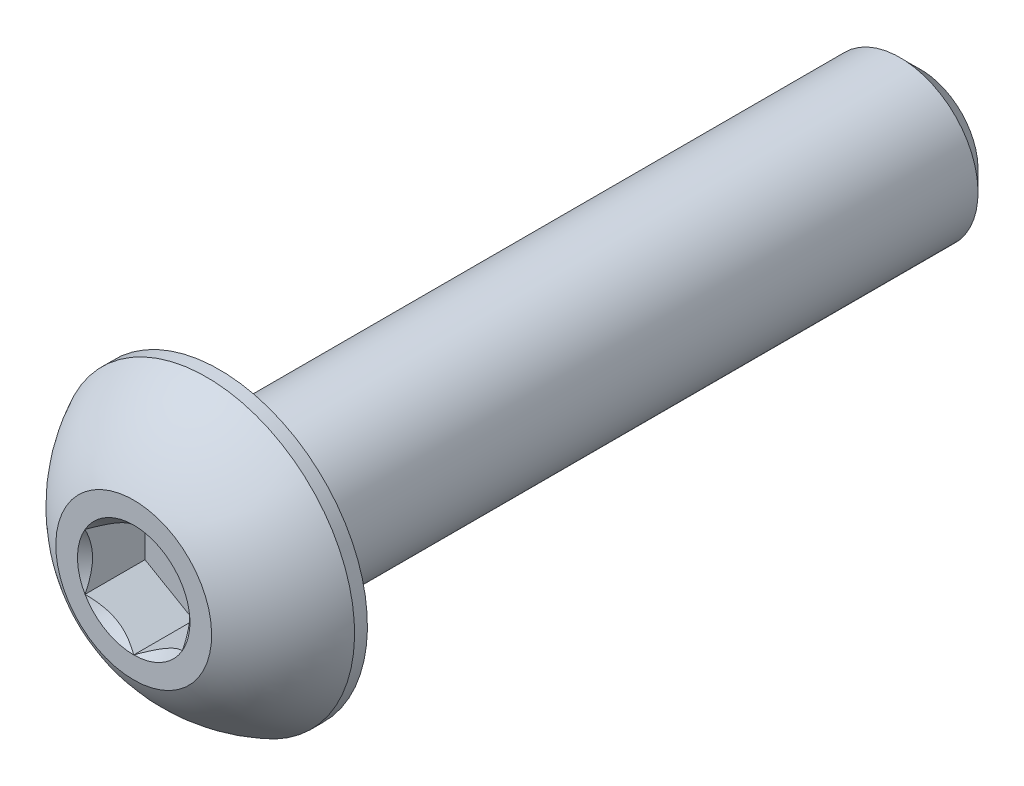
from build123d import *

# Parameters (mm, degrees)
CUT_EXTRUDE2_DEPTH = 1.54


with BuildPart() as part:
    # Sketch10 → Revolve3 (revolve)
    with BuildSketch(Plane(origin=(0, 0, 0), x_dir=(0, 0, -1), z_dir=(1, 0, 0))):
        Polygon((8.475, 2), (9, 1.475), (9, 0), (-9, 0), (-9, 2), align=None)
    revolve(axis=Axis((0, 0, 11.2), (0, 0, -1)))

    # Sketch7 → Revolve2 (revolve)
    with BuildSketch(Plane(origin=(0, 0, 0), x_dir=(0, 0, -1), z_dir=(1, 0, 0))):
        with BuildLine():
            Line((-9.33, 3.8), (-9, 3.8))
            Line((-9, 3.8), (-9, 0))
            Line((-9, 0), (-11.2, 0))
            Line((-11.2, 0), (-11.2, 2))
            ThreePointArc((-11.2, 2), (-10.406499853, 3.047002626), (-9.33, 3.8))
        make_face()
    revolve(axis=Axis((0, 0, 11.2), (0, 0, -1)))

    # Sketch5 → Cut-Extrude2 (cut)
    with BuildSketch(Plane.XY.offset(11.2)):
        Polygon((1.25, -0.721687836), (1.25, 0.721687836), (0, 1.443375673), (-1.25, 0.721687836), (-1.25, -0.721687836), (0, -1.443375673), align=None)
    extrude(amount=-CUT_EXTRUDE2_DEPTH, mode=Mode.SUBTRACT)

    # Cut-Extrude3 cone 1 section (through the dimple's axis) → Cut-Extrude3 (revolve, cut)
    with BuildSketch(Plane(origin=(0, 0, 11.2), x_dir=(0, -1, 0), z_dir=(1, 0, 0))):
        Polygon((0, 0), (1.443375673, 0), (0, 1.443375673), align=None)
    revolve(axis=Axis((0, 0, 11.2), (0, 0, -1)), mode=Mode.SUBTRACT)


solid = part.part
